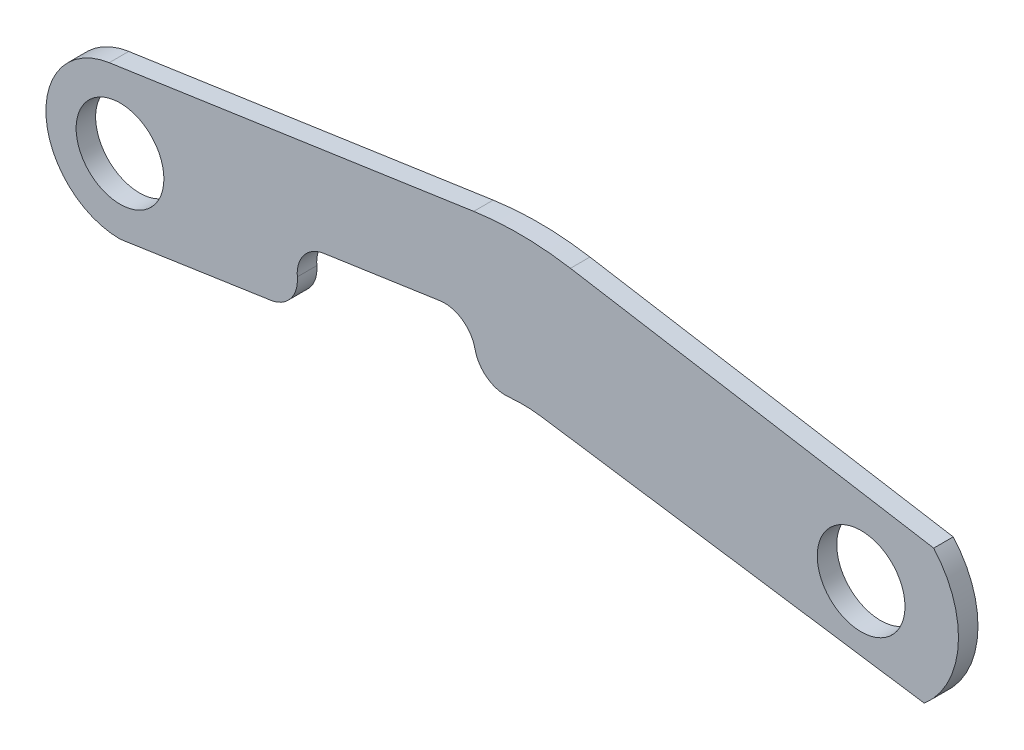
from build123d import *

# Parameters (mm, degrees)
SKETCH1_R           = 14.2875
BOSS_EXTRUDE1_DEPTH = 6.35
FILLET2_R           = 101.6
FILLET4_R           = 10.16
FILLET5_R           = 10.16
FILLET6_R           = 10.16
FILLET7_R           = 43.18
FILLET8_R           = 10.16


with BuildPart() as part:
    # Sketch1 → Boss-Extrude1 (new body)
    with BuildSketch(Plane.XY):
        with BuildLine():
            Line((-244.803394078, 23.800923648), (-110.363, 43.529137522))
            Line((-110.363, 43.529137522), (23.636021604, 21.139651339))
            ThreePointArc((23.636021604, 21.139651339), (31.638059922, -2.139986064), (20.574, -24.13))
            Line((20.574, -24.13), (-110.363, -4.730862478))
            Line((-110.363, -4.730862478), (-124.309464555, -6.804936239))
            Line((-124.309464555, -6.804936239), (-127.066874452, 11.985780223))
            Line((-127.066874452, 11.985780223), (-184.996538861, 3.484995791))
            Line((-184.996538861, 3.484995791), (-182.186210881, -15.412181497))
            Line((-182.186210881, -15.412181497), (-241.3, -24.203395818))
            ThreePointArc((-241.3, -24.203395818), (-265.365994979, -1.829751605), (-244.803394078, 23.800923648))
        make_face()
        with Locations((-241.3, -0.073395818)):
            Circle(SKETCH1_R, mode=Mode.SUBTRACT)
        Circle(SKETCH1_R, mode=Mode.SUBTRACT)
    extrude(amount=BOSS_EXTRUDE1_DEPTH)

    # Fillet2
    fillet2_edges = [part.edges().sort_by_distance(p)[0] for p in [
        (-110.363, 43.529137522, 3.175),
    ]]
    fillet(fillet2_edges, radius=FILLET2_R)

    # Fillet4
    fillet4_edges = [part.edges().sort_by_distance(p)[0] for p in [
        (-127.066874452, 11.985780223, 3.175),
    ]]
    fillet(fillet4_edges, radius=FILLET4_R)

    # Fillet5
    fillet5_edges = [part.edges().sort_by_distance(p)[0] for p in [
        (-184.996538861, 3.484995791, 3.175),
    ]]
    fillet(fillet5_edges, radius=FILLET5_R)

    # Fillet6
    fillet6_edges = [part.edges().sort_by_distance(p)[0] for p in [
        (-182.186210881, -15.412181497, 3.175),
    ]]
    fillet(fillet6_edges, radius=FILLET6_R)

    # Fillet7
    fillet7_edges = [part.edges().sort_by_distance(p)[0] for p in [
        (-110.363, -4.730862478, 3.175),
    ]]
    fillet(fillet7_edges, radius=FILLET7_R)

    # Fillet8
    fillet8_edges = [part.edges().sort_by_distance(p)[0] for p in [
        (-124.309464555, -6.804936239, 3.175),
    ]]
    fillet(fillet8_edges, radius=FILLET8_R)


solid = part.part
